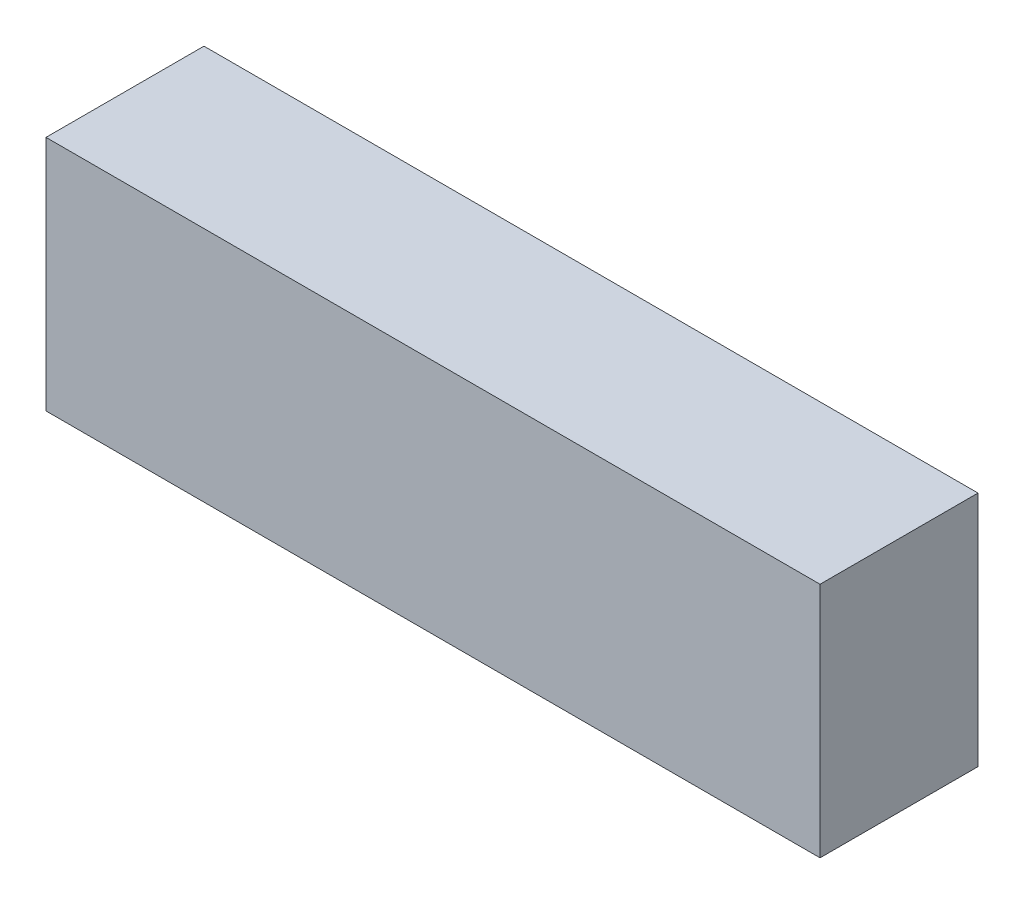
from build123d import *

# Parameters (mm, degrees)
SKETCH1_W           = 49
SKETCH1_H           = 15
BOSS_EXTRUDE1_DEPTH = 10


with BuildPart() as part:
    # Sketch1 → Boss-Extrude1 (new body)
    with BuildSketch(Plane.XY):
        with Locations((1.495310812, -1.915441176)):
            Rectangle(SKETCH1_W, SKETCH1_H)
    extrude(amount=BOSS_EXTRUDE1_DEPTH)


solid = part.part
